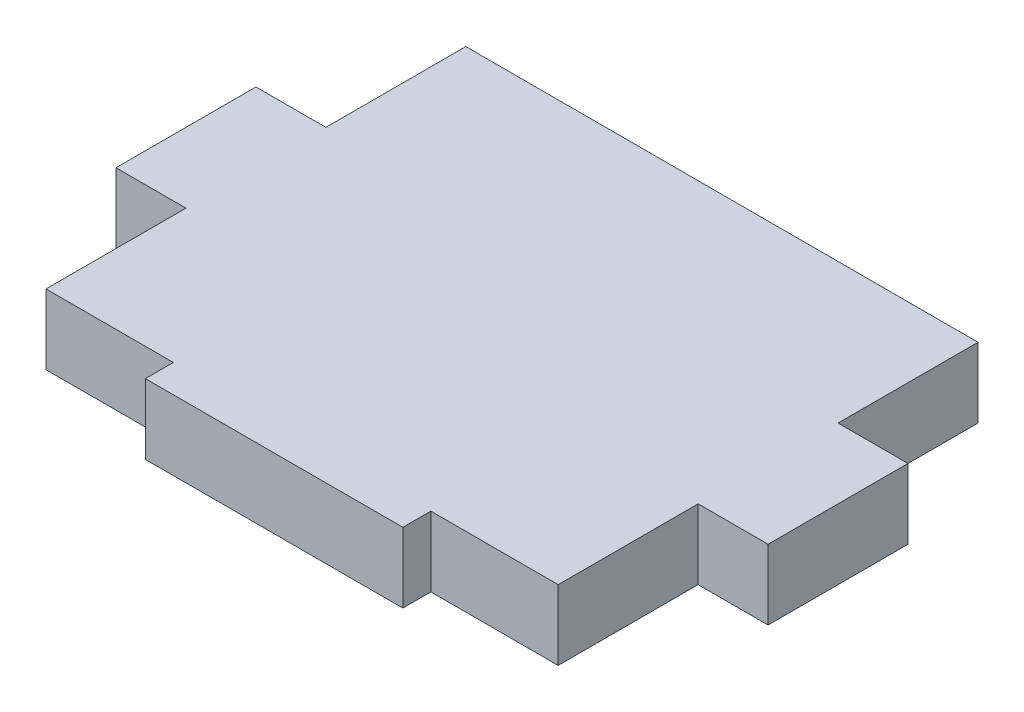
from build123d import *

# Parameters (mm, degrees)
SKETCH1_W           = 46.482
SKETCH1_H           = 38.1
BOSS_EXTRUDE1_DEPTH = 3.175
SKETCH2_W           = 23.368
SKETCH2_H           = 2.54
SKETCH2_W_2         = 6.35
SKETCH2_H_2         = 12.7
BOSS_EXTRUDE2_DEPTH = 6.35


with BuildPart() as part:
    # Sketch1 → Boss-Extrude1 (new body, symmetric)
    with BuildSketch(Plane(origin=(0, 0, 0), x_dir=(1, 0, 0), z_dir=(0, 1, 0))):
        Rectangle(SKETCH1_W, SKETCH1_H)
    extrude(amount=BOSS_EXTRUDE1_DEPTH, both=True)

    # Sketch2 → Boss-Extrude2 (add)
    with BuildSketch(Plane(origin=(0, 3.175, 0), x_dir=(1, 0, 0), z_dir=(0, 1, 0))):
        with Locations((0, -20.32)):
            Rectangle(SKETCH2_W, SKETCH2_H)
        with Locations((-26.416, 0)):
            Rectangle(SKETCH2_W_2, SKETCH2_H_2)
        with Locations((26.416, 0)):
            Rectangle(SKETCH2_W_2, SKETCH2_H_2)
    extrude(amount=-BOSS_EXTRUDE2_DEPTH)


solid = part.part
